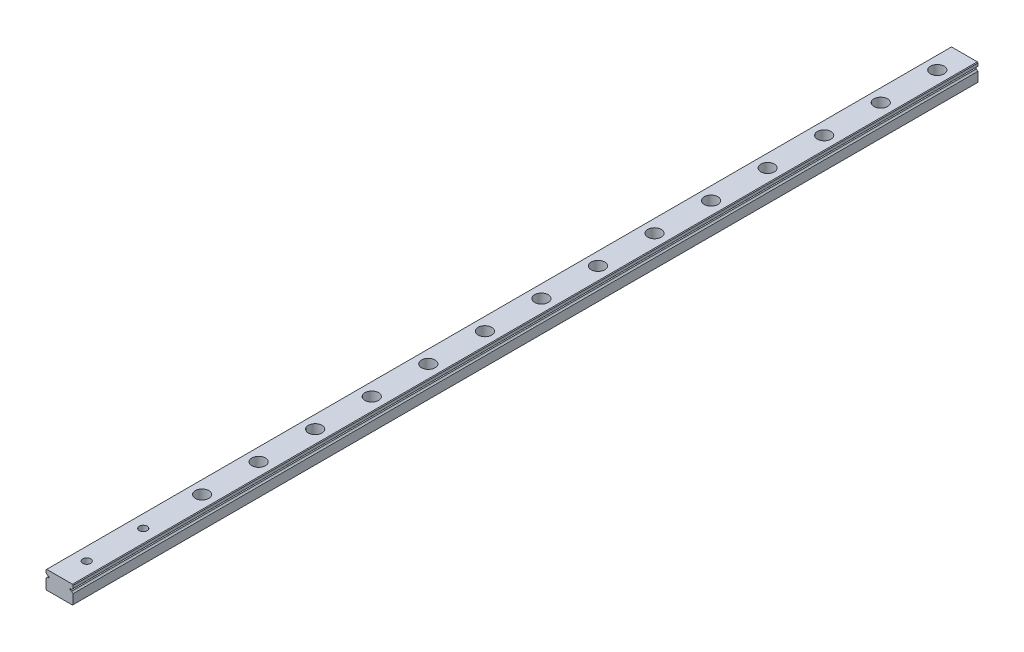
from build123d import *

# Parameters (mm, degrees)
EXTRUDE_1_DEPTH        = 400
SKETCH_2_R             = 3
SKETCH_2_R_2           = 1.75
CUT_EXTRUDE_1_DEPTH    = 4.5
SKETCH_2_2_R           = 1.75
CUT_EXTRUDE_2_DEPTH    = 9
PATTERN_LINEAR_1_COUNT = 14
PATTERN_LINEAR_1_PITCH = 25
CROQUIS1_R             = 1.75
CORTAR_EXTRUIR1_DEPTH  = 8


with BuildPart() as part:
    # Эскиз1 → Бобышка-Вытянуть1 (new body)
    with BuildSketch(Plane.XY):
        with BuildLine():
            Line((-6, 3.7), (-5.7, 4))
            Line((-5.7, 4), (5.7, 4))
            Line((5.7, 4), (6, 3.7))
            Line((6, 3.7), (6, 2.451013544))
            ThreePointArc((6, 2.451013544), (5.597935912, 2.202976267), (5.354599002, 1.798050138))
            Line((5.354599002, 1.798050138), (4.643514056, 1.798050138))
            Line((4.643514056, 1.798050138), (4.643514056, 1.201949862))
            Line((4.643514056, 1.201949862), (5.354599002, 1.201949862))
            ThreePointArc((5.354599002, 1.201949862), (5.597935912, 0.797023733), (6, 0.548986456))
            Line((6, 0.548986456), (6, -3.7))
            Line((6, -3.7), (5.7, -4))
            Line((5.7, -4), (-5.7, -4))
            Line((-5.7, -4), (-6, -3.7))
            Line((-6, -3.7), (-6, 0.548986456))
            ThreePointArc((-6, 0.548986456), (-5.597935912, 0.797023733), (-5.354599002, 1.201949862))
            Line((-5.354599002, 1.201949862), (-4.643514056, 1.201949862))
            Line((-4.643514056, 1.201949862), (-4.643514056, 1.798050138))
            Line((-4.643514056, 1.798050138), (-5.354599002, 1.798050138))
            ThreePointArc((-5.354599002, 1.798050138), (-5.597935912, 2.202976267), (-6, 2.451013544))
            Line((-6, 2.451013544), (-6, 3.7))
        make_face()
    extrude(amount=EXTRUDE_1_DEPTH)

    # Эскиз2 → Вырез-Вытянуть1 (cut)
    with BuildSketch(Plane(origin=(0, 4, 0), x_dir=(1, 0, 0), z_dir=(0, 1, 0))):
        with Locations((0, -12)):
            Circle(SKETCH_2_R)
        with Locations((0, -12)):
            Circle(SKETCH_2_R_2, mode=Mode.SUBTRACT)
    cut_extrude_1 = extrude(amount=-CUT_EXTRUDE_1_DEPTH, mode=Mode.SUBTRACT)

    # Эскиз2<2> → Вырез-Вытянуть2 (cut, through all)
    with BuildSketch(Plane(origin=(0, 4, 0), x_dir=(1, 0, 0), z_dir=(0, 1, 0))):
        with Locations((0, -12)):
            Circle(SKETCH_2_2_R)
    cut_extrude_2 = extrude(amount=-CUT_EXTRUDE_2_DEPTH, mode=Mode.SUBTRACT)

    # Линейный массив1: Вырез-Вытянуть1, Вырез-Вытянуть2 ×14
    with Locations(*[(0, 0, i * PATTERN_LINEAR_1_PITCH) for i in range(1, PATTERN_LINEAR_1_COUNT)]):
        add(cut_extrude_1, mode=Mode.SUBTRACT)
        add(cut_extrude_2, mode=Mode.SUBTRACT)

    # Croquis1 → Cortar-Extruir1 (cut)
    with BuildSketch(Plane(origin=(0, 4, 0), x_dir=(1, 0, 0), z_dir=(0, 1, 0))):
        with Locations((0, -388)):
            Circle(CROQUIS1_R)
        with Locations((0, -363)):
            Circle(CROQUIS1_R)
    extrude(amount=-CORTAR_EXTRUIR1_DEPTH, mode=Mode.SUBTRACT)


solid = part.part
